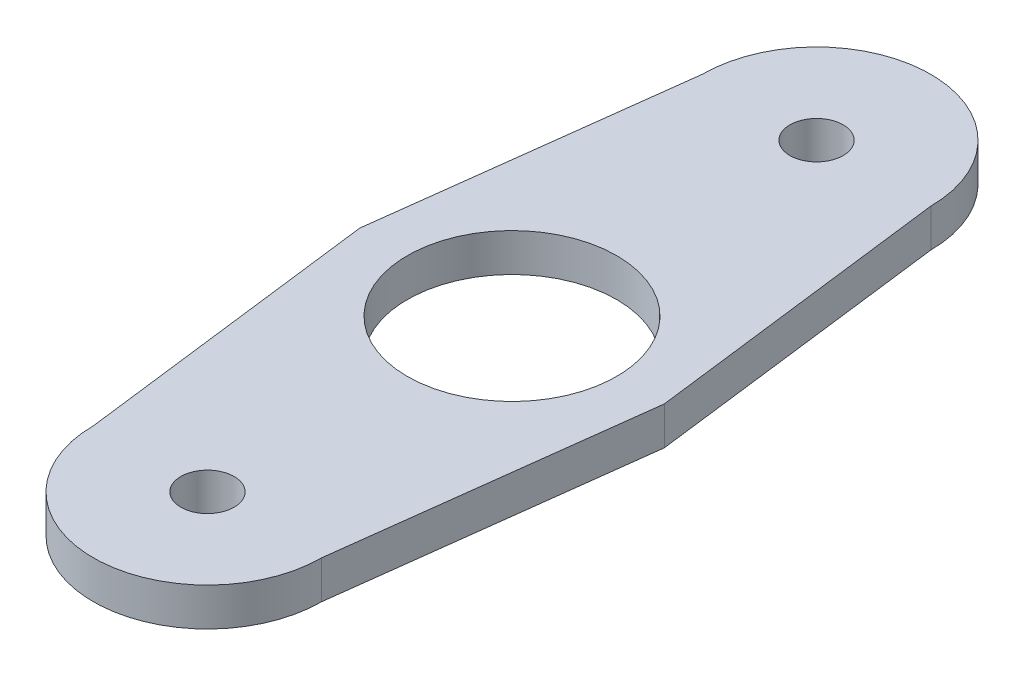
from build123d import *

# Parameters (mm, degrees)
SKETCH1_R           = 4.445
SKETCH1_R_2         = 17.4625
BOSS_EXTRUDE1_DEPTH = 6.35


with BuildPart() as part:
    # Sketch1 → Boss-Extrude1 (new body)
    with BuildSketch(Plane(origin=(0, 0, 0), x_dir=(1, 0, 0), z_dir=(0, 1, 0))):
        with BuildLine():
            ThreePointArc((-19.05, -50.8), (0, -69.85), (19.05, -50.8))
            Line((19.05, -50.8), (25.4, 0))
            Line((25.4, 0), (19.05, 50.8))
            ThreePointArc((19.05, 50.8), (0, 69.85), (-19.05, 50.8))
            Line((-19.05, 50.8), (-25.4, 0))
            Line((-25.4, 0), (-19.05, -50.8))
        make_face()
        with Locations((0, -50.8)):
            Circle(SKETCH1_R, mode=Mode.SUBTRACT)
        Circle(SKETCH1_R_2, mode=Mode.SUBTRACT)
        with Locations((0, 50.8)):
            Circle(SKETCH1_R, mode=Mode.SUBTRACT)
    extrude(amount=BOSS_EXTRUDE1_DEPTH)


solid = part.part
